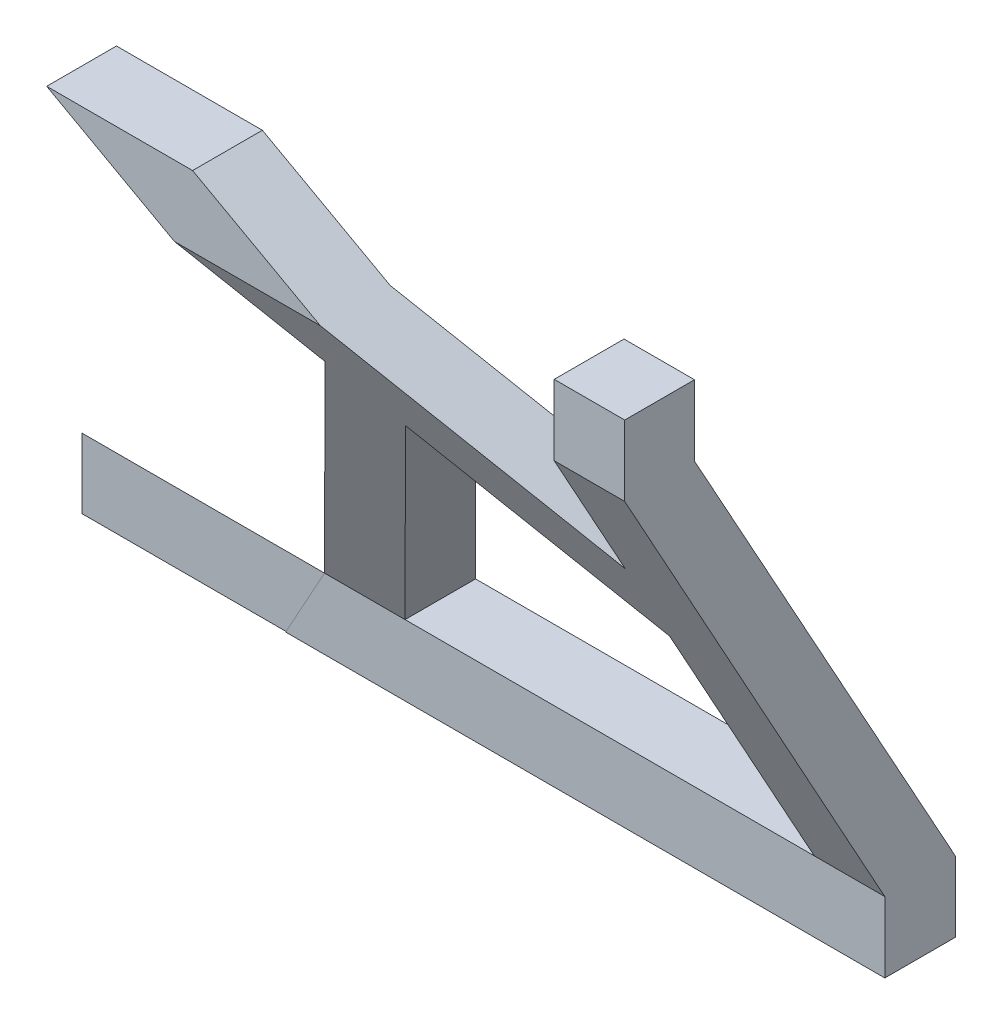
from build123d import *

# Parameters (mm, degrees)
SKETCH8_W               = 85
SKETCH8_H               = 10
BOSS_EXTRUDE4_DEPTH     = 10
SKETCH9_W               = 82
SKETCH9_H               = 9.9
BOSS_EXTRUDE5_DEPTH     = 10
CUT_EXTRUDE2_DEPTH      = 176.278228509
CUT_EXTRUDE2_DEPTH_BACK = 176.278228509
BOSS_EXTRUDE6_DEPTH     = 114


with BuildPart() as part:
    # Sketch8 → Boss-Extrude4 (new body)
    with BuildSketch(Plane(origin=(0, 0, 0), x_dir=(1, 0, 0), z_dir=(0, 1, 0))):
        with Locations((90.205142442, -69.45)):
            Rectangle(SKETCH8_W, SKETCH8_H)
    extrude(amount=BOSS_EXTRUDE4_DEPTH)


with BuildPart() as body_2:
    # Sketch9 → Boss-Extrude5 (new body)
    with BuildSketch(Plane(origin=(0, 87, 0), x_dir=(1, 0, 0), z_dir=(0, 1, 0))):
        with Locations((91.705142442, -32.5)):
            Rectangle(SKETCH9_W, SKETCH9_H)
    extrude(amount=-BOSS_EXTRUDE5_DEPTH)


    add(part.part)  # loft1 joins it to this body
    # loft from a face of the part (loft1)
    loft([body_2.faces().sort_by_distance((91.705142442, 77, 32.5))[0], body_2.faces().sort_by_distance((90.205142442, 10, 69.45))[0]])

    # Sketch1 → Cut-Extrude2 (cut, two sides)
    with BuildSketch(Plane.XY) as cut_extrude2_sk:
        Polygon((122.705142442, 87), (71.403683768, 87), (122.705142442, 58.6920409), align=None)
        Polygon((64.644486366, 10), (93.961994057, 63.13102594), (122.705142442, 47.270660759), (122.705142442, 10), align=None)
        Polygon((47.705142442, 0), (40.860670667, 0), (50.705142442, 87), (85.206484761, 67.96228426), align=None)
    extrude(amount=CUT_EXTRUDE2_DEPTH, mode=Mode.SUBTRACT)
    extrude(cut_extrude2_sk.sketch, amount=-CUT_EXTRUDE2_DEPTH_BACK, mode=Mode.SUBTRACT)

    # Sketch10 → Boss-Extrude6 (add)
    with BuildSketch(Plane(origin=(132.705142442, 0, 0), x_dir=(0, 0, -1), z_dir=(1, 0, 0))):
        Polygon((-64.55, 9.9), (-64.55, 0), (-74.45, 0), align=None)
    extrude(amount=-BOSS_EXTRUDE6_DEPTH)


with BuildPart() as body_2_2:
    # Mirror9: mirrored copy
    add(body_2.part.mirror(Plane.XY))


solid = body_2_2.part
